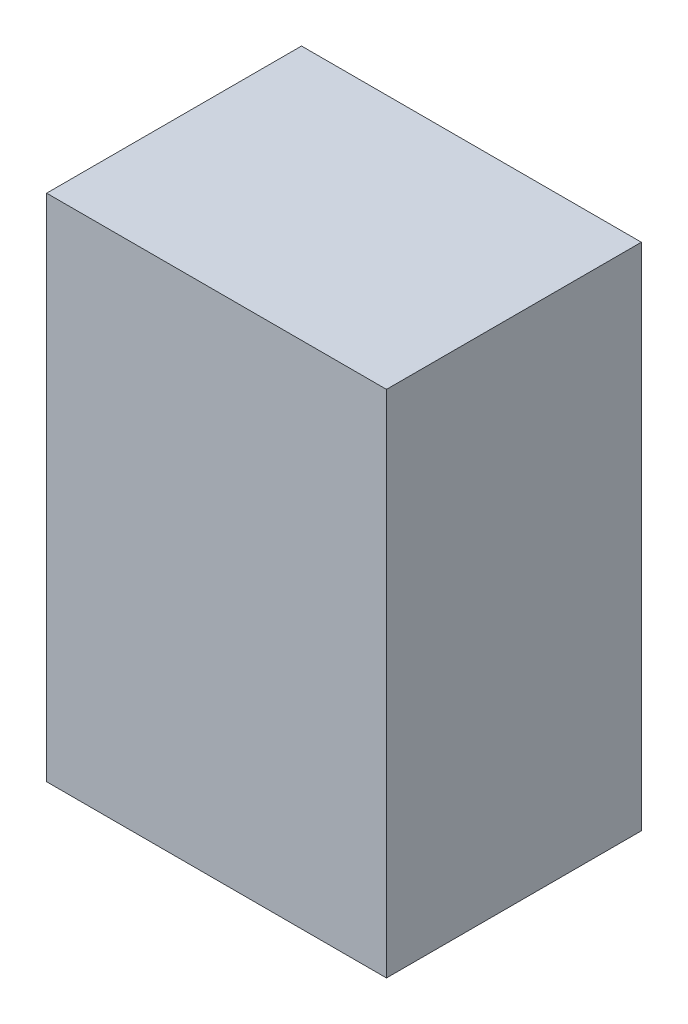
from build123d import *

# Parameters (mm, degrees)
SKETCH1_W      = 80
SKETCH1_H      = 60
EXTRUDE1_DEPTH = 120


with BuildPart() as part:
    # Sketch1 → Extrude1 (new body)
    with BuildSketch(Plane(origin=(0, 0, 0), x_dir=(1, 0, 0), z_dir=(0, 1, 0))):
        with Locations((-40, 30)):
            Rectangle(SKETCH1_W, SKETCH1_H)
    extrude(amount=EXTRUDE1_DEPTH)


solid = part.part
